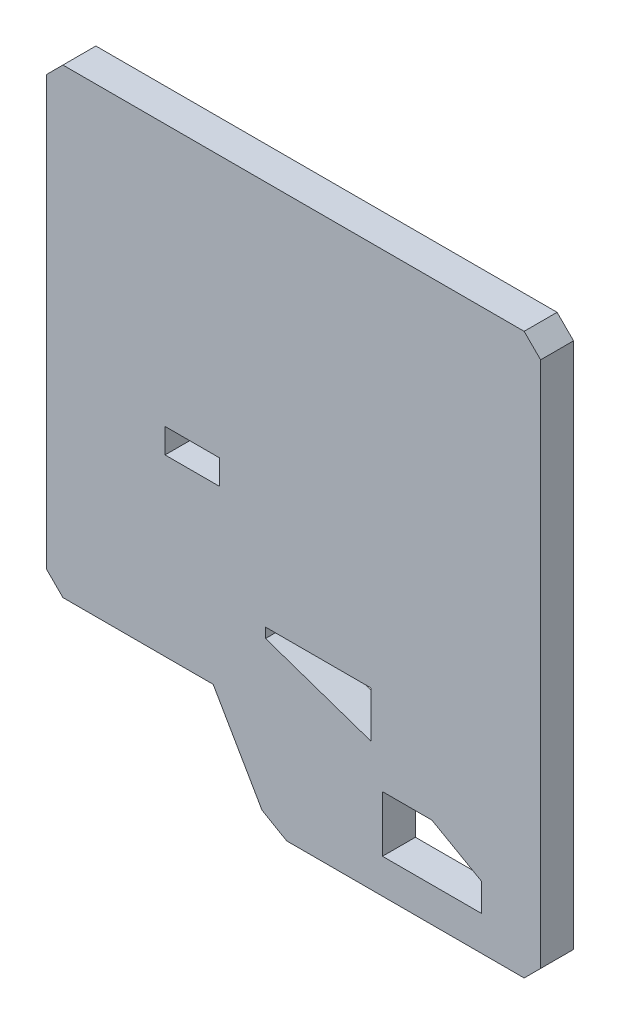
from build123d import *

# Parameters (mm, degrees)
SKETCH2_W           = 33
SKETCH2_H           = 15
BOSS_EXTRUDE1_DEPTH = 20
SKETCH8_R           = 40
SKETCH8_R_2         = 15
BOSS_EXTRUDE3_DEPTH = 10
LPATTERN1_COUNT     = 2
LPATTERN1_PITCH     = 70


with BuildPart() as part:
    # Sketch2 → Boss-Extrude1 (new body)
    with BuildSketch(Plane.XY):
        Polygon((-140, -110), (-48.782097787, -110), (-19.141081636, -161.339745962), (-4.141081636, -170), (140, -170), (150, -160), (150, 160), (140, 170), (-140, 170), (-150, 160), (-150, -100), align=None)
        Polygon((84, -115), (114, -132), (114, -149), (54, -149), (54, -115), align=None, mode=Mode.SUBTRACT)
        Polygon((47, -92), (-17, -70), (-17, -64), (47, -64), align=None, mode=Mode.SUBTRACT)
        with Locations((-61.5, 3.5)):
            Rectangle(SKETCH2_W, SKETCH2_H, mode=Mode.SUBTRACT)
    extrude(amount=BOSS_EXTRUDE1_DEPTH)

    # Sketch8 → Boss-Extrude3 (add)
    with BuildSketch(Plane.XZ.offset(110)):
        with BuildLine():
            Line((-145, 0), (-145, -80))
            ThreePointArc((-145, -80), (-111.780674121, -130.503487353), (-52.250827824, -120))
            Line((-52.250827824, -120), (10, -120))
            ThreePointArc((10, -120), (50, -80), (10, -40))
            Line((10, -40), (-35, -40))
            Line((-35, -40), (-35, 0))
            Line((-35, 0), (-145, 0))
        make_face()
        with Locations((-90, -80)):
            Circle(SKETCH8_R, mode=Mode.SUBTRACT)
        with Locations((10, -80)):
            Circle(SKETCH8_R_2, mode=Mode.SUBTRACT)
    boss_extrude3 = extrude(amount=-BOSS_EXTRUDE3_DEPTH)

    # LPattern1: Boss-Extrude3 ×2
    with Locations(*[(0, i * LPATTERN1_PITCH, 0) for i in range(1, LPATTERN1_COUNT)]):
        add(boss_extrude3)


solid = part.part
